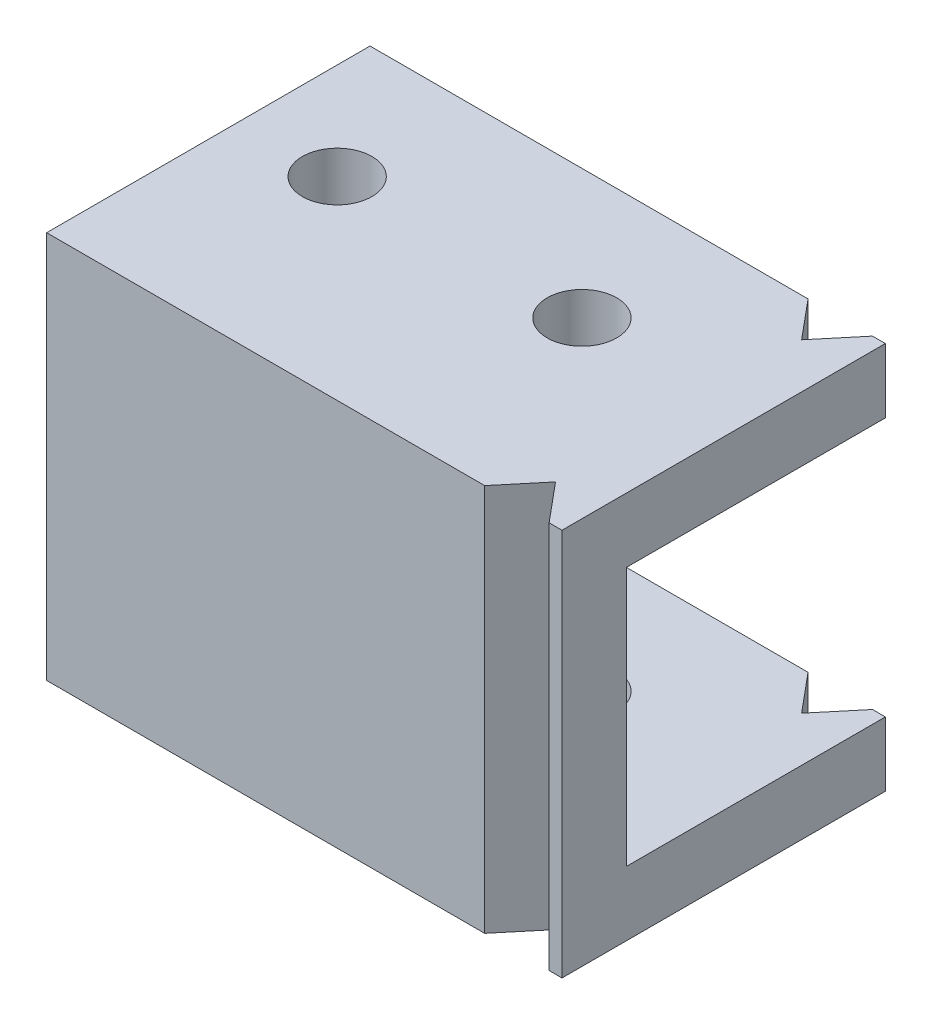
from build123d import *

# Parameters (mm, degrees)
BOSS_EXTRUDE1_DEPTH = 40
SKETCH5_R           = 2.7
CUT_EXTRUDE1_DEPTH  = 31.1


with BuildPart() as part:
    # Sketch1 → Boss-Extrude1 (new body)
    with BuildSketch(Plane(origin=(0, 0, 0), x_dir=(0, 0, -1), z_dir=(1, 0, 0))):
        Polygon((10.05, -10.05), (10.05, -15.05), (-15.05, -15.05), (-15.05, 15.05), (10.05, 15.05), (10.05, 10.05), (-10.05, 10.05), (-10.05, -10.05), align=None)
    extrude(amount=BOSS_EXTRUDE1_DEPTH)

    # Sketch5 → Cut-Extrude1 (cut, through all)
    with BuildSketch(Plane(origin=(0, 15.05, 0), x_dir=(1, 0, 0), z_dir=(0, 1, 0))):
        with Locations((7.5, 0)):
            Circle(SKETCH5_R)
        with Locations((26.5, 0)):
            Circle(SKETCH5_R)
        Polygon((34, -15.05), (36.5, -12.05), (39, -15.05), align=None)
        Polygon((36.5, 7.05), (39, 10.05), (34, 10.05), align=None)
    extrude(amount=-CUT_EXTRUDE1_DEPTH, mode=Mode.SUBTRACT)


solid = part.part
